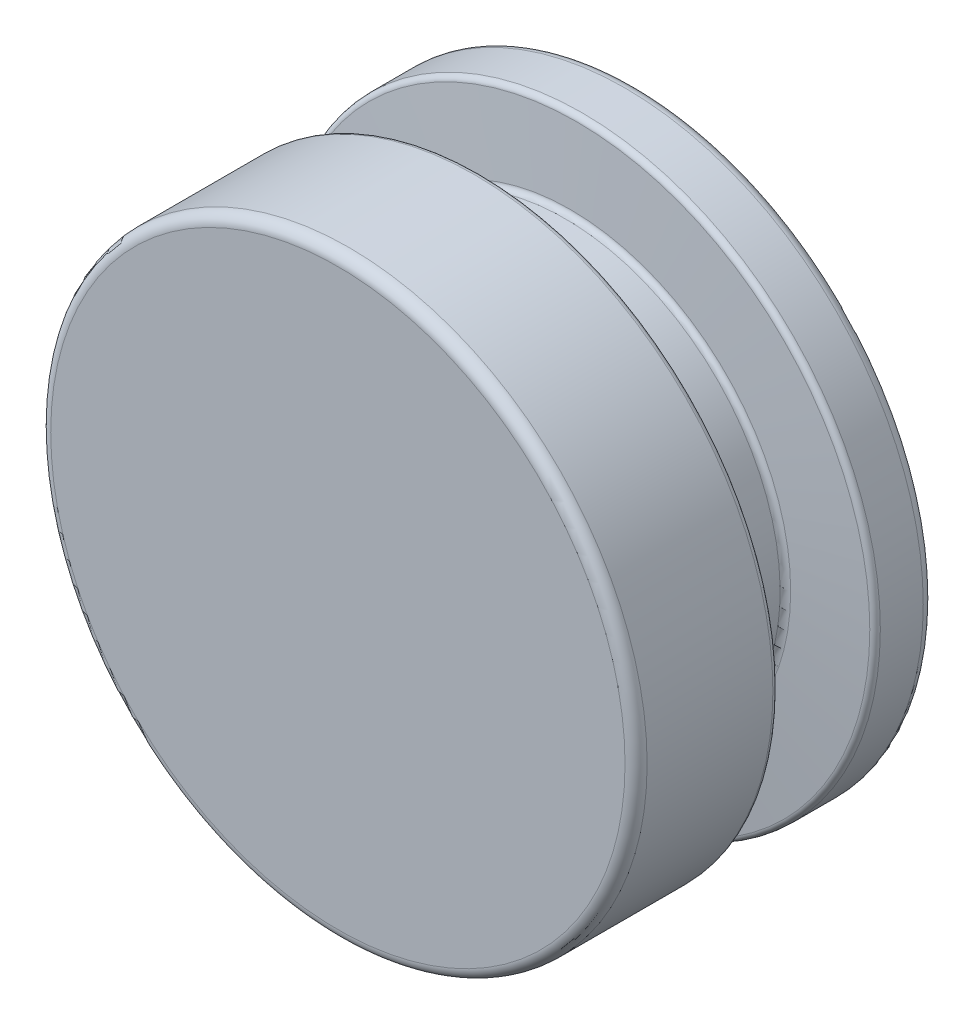
from build123d import *

# Parameters (mm, degrees)
SKETCH1_R                = 68.57365
BOSS_EXTRUDE1_DEPTH      = 17.78
BOSS_EXTRUDE1_DEPTH_BACK = 50.8
FILLET1_R                = 1.27
FILLET2_R                = 2.54


with BuildPart() as part:
    # Sketch1 → Boss-Extrude1 (new body, two sides)
    with BuildSketch(Plane.XY) as boss_extrude1_sk:
        Circle(SKETCH1_R)
    extrude(amount=BOSS_EXTRUDE1_DEPTH)
    extrude(boss_extrude1_sk.sketch, amount=-BOSS_EXTRUDE1_DEPTH_BACK)

    # Sketch2 → Cut-Revolve1 (revolve, cut)
    with BuildSketch(Plane(origin=(0, 0, 0), x_dir=(0, 0, -1), z_dir=(1, 0, 0))):
        Polygon((16.51, 49.52365), (35.56, 49.52365), (37.22665904, 68.57365), (14.84334096, 68.57365), align=None)
    revolve(axis=Axis((0, 0, 17.78), (0, 0, -1)), mode=Mode.SUBTRACT)

    # Fillet1
    fillet1_edges = [part.edges().sort_by_distance(p)[0] for p in [
        (-48.488892926, -48.488892926, -14.84334096),
        (-48.488892926, -48.488892926, -37.22665904),
        (0, -49.52365, -35.56),
        (0, -49.52365, -16.51),
    ]]
    fillet(fillet1_edges, radius=FILLET1_R)

    # Fillet2
    fillet2_edges = [part.edges().sort_by_distance(p)[0] for p in [
        (-68.57365, 0, 17.78),
        (-68.57365, 0, -50.8),
    ]]
    fillet(fillet2_edges, radius=FILLET2_R)


solid = part.part
